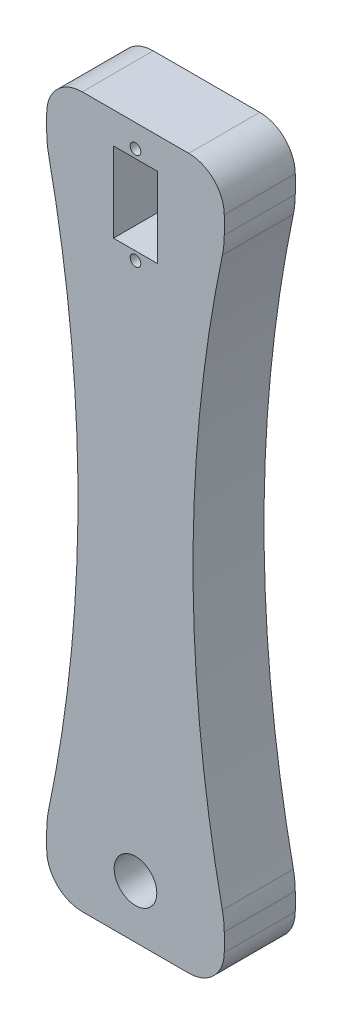
from build123d import *

# Parameters (mm, degrees)
SKETCH1_W               = 50
SKETCH1_H               = 200
BOSS_EXTRUDE1_DEPTH     = 20
SKETCH2_R               = 6
CUT_EXTRUDE1_DEPTH      = 84
FILLET1_R               = 10
SKETCH4_R               = 6
SKETCH4_R_2             = 1.5
CUT_EXTRUDE2_DEPTH      = 33
CUT_EXTRUDE3_DEPTH      = 1
CUT_EXTRUDE3_DEPTH_BACK = 53


with BuildPart() as part:
    # Sketch1 → Boss-Extrude1 (new body)
    with BuildSketch(Plane.XY):
        with Locations((25, -100)):
            Rectangle(SKETCH1_W, SKETCH1_H)
    extrude(amount=BOSS_EXTRUDE1_DEPTH)

    # Sketch2 → Cut-Extrude1 (cut)
    with BuildSketch(Plane.XY.offset(20)):
        with Locations((25, -185)):
            Circle(SKETCH2_R)
        with Locations((25, -15)):
            Circle(SKETCH2_R)
    extrude(amount=-CUT_EXTRUDE1_DEPTH, mode=Mode.SUBTRACT)

    # Fillet1
    fillet1_edges = [part.edges().sort_by_distance(p)[0] for p in [
        (0, 0, 10),
        (50, 0, 10),
        (50, -200, 10),
        (0, -200, 10),
    ]]
    fillet(fillet1_edges, radius=FILLET1_R)

    # Sketch4 → Cut-Extrude2 (cut)
    with BuildSketch(Plane.XY.offset(20)):
        Polygon((31.2, -8.8), (25, -8.8), (18.8, -8.8), (18.8, -31.3), (25, -31.3), (31.2, -31.3), align=None)
        with Locations((25, -15)):
            Circle(SKETCH4_R, mode=Mode.SUBTRACT)
        with Locations((25, -33.7)):
            Circle(SKETCH4_R_2)
        with Locations((25, -6.4)):
            Circle(SKETCH4_R_2)
    extrude(amount=-CUT_EXTRUDE2_DEPTH, mode=Mode.SUBTRACT)

    # Sketch5 → Cut-Extrude3 (cut, two sides)
    with BuildSketch(Plane.XY.offset(20)) as cut_extrude3_sk:
        with BuildLine():
            ThreePointArc((49.469995195, -179.879518072), (49.867145794, -182.426080796), (50, -185))
            Line((50, -185), (50, -15))
            ThreePointArc((50, -15), (49.867145794, -17.573919204), (49.469995195, -20.120481928))
            ThreePointArc((49.469995195, -20.120481928), (41.201920232, -100), (49.469995195, -179.879518072))
        make_face()
        with BuildLine():
            ThreePointArc((0.530004805, -20.120481928), (0.132854206, -17.573919204), (0, -15))
            Line((0, -15), (0, -185))
            ThreePointArc((0, -185), (0.132854206, -182.426080796), (0.530004805, -179.879518072))
            ThreePointArc((0.530004805, -179.879518072), (8.798079768, -100), (0.530004805, -20.120481928))
        make_face()
    extrude(amount=CUT_EXTRUDE3_DEPTH, mode=Mode.SUBTRACT)
    extrude(cut_extrude3_sk.sketch, amount=-CUT_EXTRUDE3_DEPTH_BACK, mode=Mode.SUBTRACT)


solid = part.part
